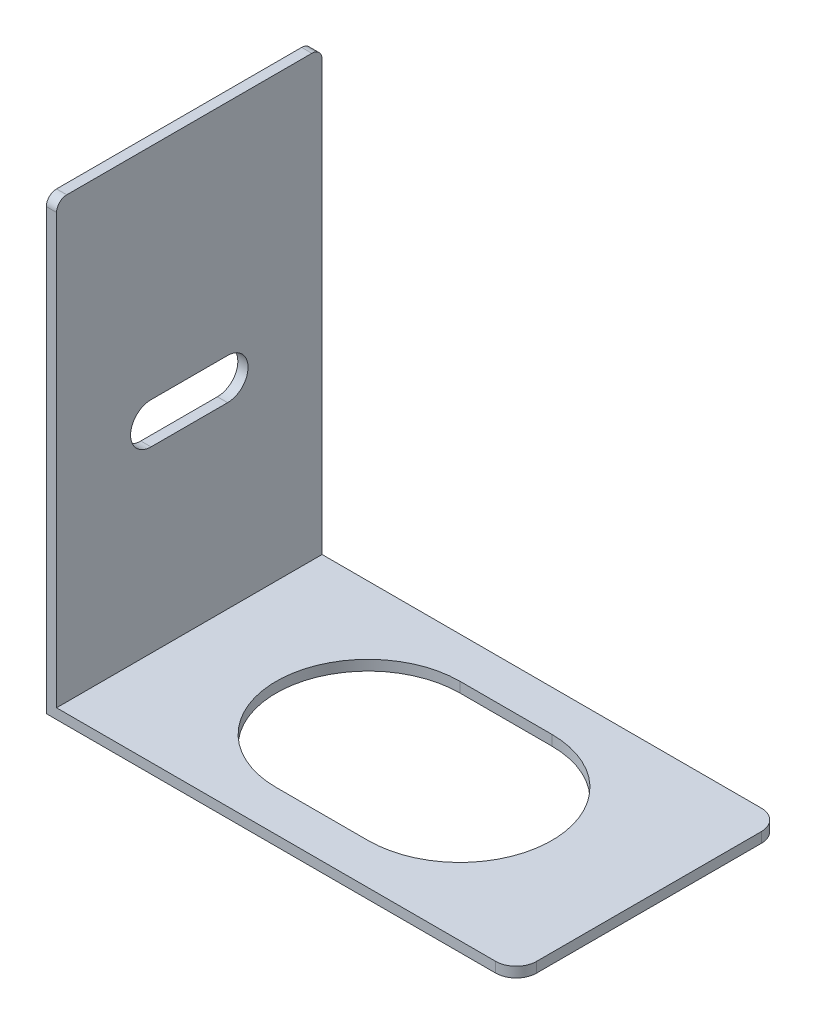
from build123d import *

# Parameters (mm, degrees)
BOSS_EXTRUDE1_DEPTH = 1
SKETCH2_W           = 1
SKETCH2_H           = 26
BOSS_EXTRUDE2_DEPTH = 43
CUT_EXTRUDE1_DEPTH  = 1
FILLET1_R           = 1


with BuildPart() as part:
    # Sketch1 → Boss-Extrude1 (new body)
    with BuildSketch(Plane(origin=(0, 0, 0), x_dir=(1, 0, 0), z_dir=(0, 1, 0))):
        with BuildLine():
            Line((-23, 13), (21, 13))
            ThreePointArc((21, 13), (22.414213562, 12.414213562), (23, 11))
            Line((23, 11), (23, -11))
            ThreePointArc((23, -11), (22.414213562, -12.414213562), (21, -13))
            Line((21, -13), (-23, -13))
            Line((-23, -13), (-23, 13))
        make_face()
        with BuildLine():
            Line((-4.5, 9), (4.5, 9))
            ThreePointArc((4.5, 9), (13.5, 0), (4.5, -9))
            Line((4.5, -9), (-4.5, -9))
            ThreePointArc((-4.5, -9), (-13.5, 0), (-4.5, 9))
        make_face(mode=Mode.SUBTRACT)
    extrude(amount=BOSS_EXTRUDE1_DEPTH)

    # Sketch2 → Boss-Extrude2 (add)
    with BuildSketch(Plane(origin=(0, 1, 0), x_dir=(1, 0, 0), z_dir=(0, 1, 0))):
        with Locations((-22.5, 0)):
            Rectangle(SKETCH2_W, SKETCH2_H)
    extrude(amount=BOSS_EXTRUDE2_DEPTH)

    # Sketch3 → Cut-Extrude1 (cut)
    with BuildSketch(Plane(origin=(-22, 0, 0), x_dir=(0, 0, -1), z_dir=(1, 0, 0))):
        with BuildLine():
            Line((-3.75, 22.5), (3.75, 22.5))
            ThreePointArc((3.75, 22.5), (5.75, 20.5), (3.75, 18.5))
            Line((3.75, 18.5), (-3.75, 18.5))
            ThreePointArc((-3.75, 18.5), (-5.75, 20.5), (-3.75, 22.5))
        make_face()
    extrude(amount=-CUT_EXTRUDE1_DEPTH, mode=Mode.SUBTRACT)

    # Fillet1
    fillet1_edges = [part.edges().sort_by_distance(p)[0] for p in [
        (-22.5, 44, -13),
        (-22.5, 44, 13),
    ]]
    fillet(fillet1_edges, radius=FILLET1_R)


solid = part.part
